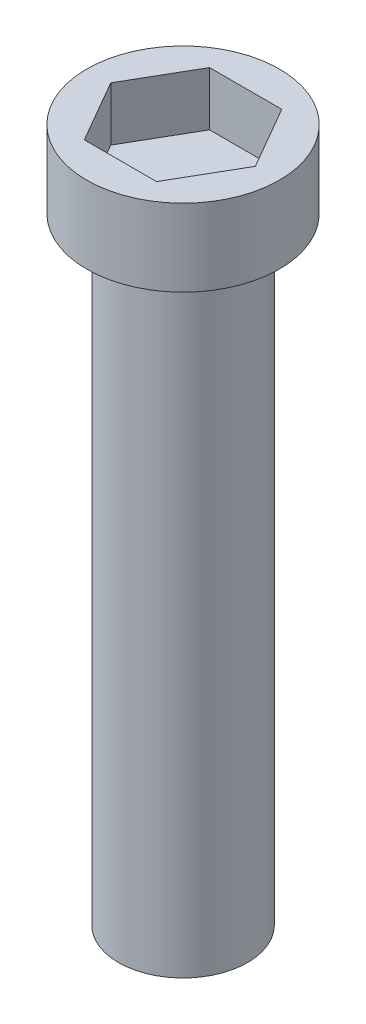
from build123d import *

# Parameters (mm, degrees)
CROQUIS1_R                 = 5
SALIENTE_EXTRUIR1_DEPTH    = 4
CROQUIS2_R                 = 3.35
SALIENTE_EXTRUIR2_DEPTH    = 32
CORTAR_EXTRUIR1_DEPTH      = 1.3
CORTAR_EXTRUIR1_DEPTH_BACK = 2.5


with BuildPart() as part:
    # Croquis1 → Saliente-Extruir1 (new body)
    with BuildSketch(Plane(origin=(0, 0, 0), x_dir=(1, 0, 0), z_dir=(0, 1, 0))):
        Circle(CROQUIS1_R)
    extrude(amount=SALIENTE_EXTRUIR1_DEPTH)

    # Croquis2 → Saliente-Extruir2 (add)
    with BuildSketch(Plane(origin=(0, 0, 0), x_dir=(1, 0, 0), z_dir=(0, 1, 0))):
        Circle(CROQUIS2_R)
    extrude(amount=-SALIENTE_EXTRUIR2_DEPTH)

    # Croquis4 → Cortar-Extruir1 (cut, two sides)
    with BuildSketch(Plane(origin=(0, 3.7, 0), x_dir=(1, 0, 0), z_dir=(0, 1, 0))) as cortar_extruir1_sk:
        Polygon((3.75277675, 0), (1.876388375, 3.25), (-1.876388375, 3.25), (-3.75277675, 0), (-1.876388375, -3.25), (1.876388375, -3.25), align=None)
    extrude(amount=CORTAR_EXTRUIR1_DEPTH, mode=Mode.SUBTRACT)
    extrude(cortar_extruir1_sk.sketch, amount=-CORTAR_EXTRUIR1_DEPTH_BACK, mode=Mode.SUBTRACT)


solid = part.part
